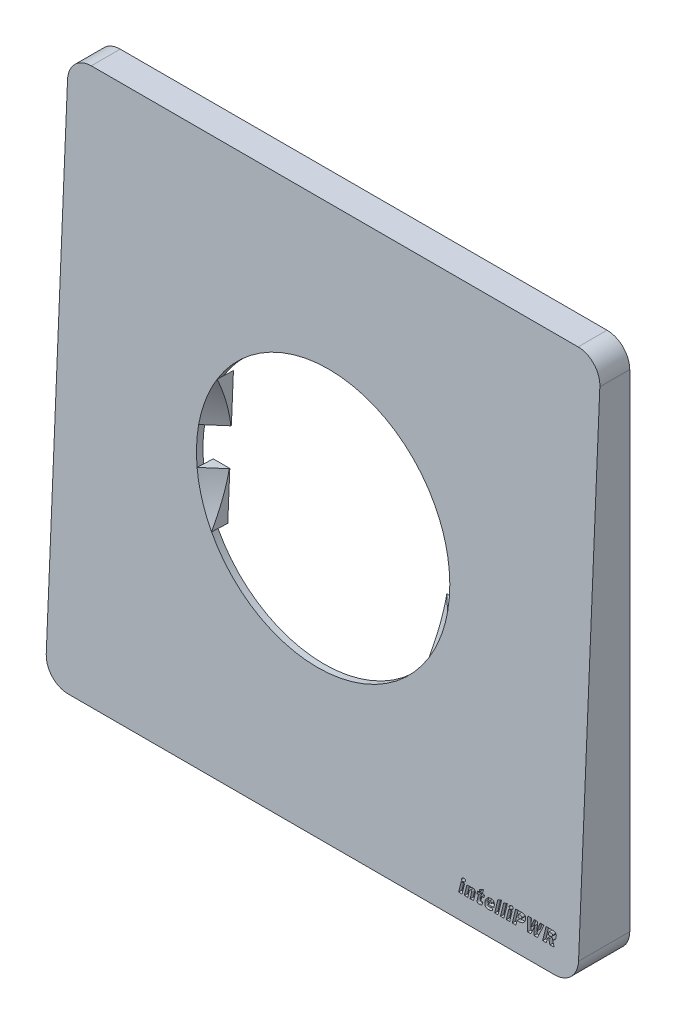
from build123d import *

# Parameters (mm, degrees)
EXTRUDE_THIN1_DEPTH         = 8
CUT_EXTRUDE2_DEPTH          = 120
BOSS_EXTRUDE1_DEPTH         = 82
CUT_EXTRUDE_THIN1_DEPTH     = 82
SKETCH8_R                   = 19.5
CUT_EXTRUDE3_DEPTH          = 82
CUT_EXTRUDE13_DEPTH         = 0.5
Y_KSEKLIK_EKSTR_ZYON1_DEPTH = 2.5
Y_KSEKLIK_EKSTR_ZYON4_REACH = 10.045
IZIM7_R                     = 5
IZIM8_W                     = 75
IZIM8_H                     = 75
KES_EKSTR_ZYON1_DEPTH       = 1.5
KES_EKSTR_ZYON2_DEPTH       = 3
IZIM11_R                    = 1.55
KES_EKSTR_ZYON3_DEPTH       = 2


with BuildPart() as part:
    # Sketch1 → Extrude-Thin1 (new body)
    with BuildSketch(Plane.XY):
        with BuildLine():
            Line((-37.5, 41), (37.5, 41))
            ThreePointArc((37.5, 41), (39.974873734, 39.974873734), (41, 37.5))
            Line((41, 37.5), (41, -37.5))
            ThreePointArc((41, -37.5), (39.974873734, -39.974873734), (37.5, -41))
            Line((37.5, -41), (-37.5, -41))
            ThreePointArc((-37.5, -41), (-39.974873734, -39.974873734), (-41, -37.5))
            Line((-41, -37.5), (-41, 37.5))
            ThreePointArc((-41, 37.5), (-39.974873734, 39.974873734), (-37.5, 41))
        make_face()
        with BuildLine():
            Line((-37.5, 40), (37.5, 40))
            ThreePointArc((37.5, 40), (39.267766953, 39.267766953), (40, 37.5))
            Line((40, 37.5), (40, -37.5))
            ThreePointArc((40, -37.5), (39.267766953, -39.267766953), (37.5, -40))
            Line((37.5, -40), (-37.5, -40))
            ThreePointArc((-37.5, -40), (-39.267766953, -39.267766953), (-40, -37.5))
            Line((-40, -37.5), (-40, 37.5))
            ThreePointArc((-40, 37.5), (-39.267766953, 39.267766953), (-37.5, 40))
        make_face(mode=Mode.SUBTRACT)
    extrude(amount=EXTRUDE_THIN1_DEPTH)

    # Sketch5 → Cut-Extrude2 (cut)
    with BuildSketch(Plane(origin=(41, 0, 0), x_dir=(0, 0, -1), z_dir=(1, 0, 0))):
        Polygon((-3.45625, 41), (-8, 41), (-8, -41), (-7.04375, -41), align=None)
    extrude(amount=-CUT_EXTRUDE2_DEPTH, mode=Mode.SUBTRACT)

    # Sketch6 → Boss-Extrude1 (add)
    with BuildSketch(Plane(origin=(41, 0, 0), x_dir=(0, 0, -1), z_dir=(1, 0, 0))):
        Polygon((-7.04375, -41), (-3.45625, 41), (-4.457206574, 41), (-8.044706574, -41), align=None)
    extrude(amount=-BOSS_EXTRUDE1_DEPTH)

    # Sketch7 → Cut-Extrude-Thin1 (cut)
    with BuildSketch(Plane(origin=(0, 0, 0), x_dir=(-1, 0, 0), z_dir=(0, 0, -1))):
        with BuildLine():
            Line((-37.5, 52), (37.5, 52))
            ThreePointArc((37.5, 52), (47.753048327, 47.753048327), (52, 37.5))
            Line((52, 37.5), (52, -37.5))
            ThreePointArc((52, -37.5), (47.753048327, -47.753048327), (37.5, -52))
            Line((37.5, -52), (-37.5, -52))
            ThreePointArc((-37.5, -52), (-47.753048327, -47.753048327), (-52, -37.5))
            Line((-52, -37.5), (-52, 37.5))
            ThreePointArc((-52, 37.5), (-47.753048327, 47.753048327), (-37.5, 52))
        make_face()
        with BuildLine():
            Line((-37.5, 41), (37.5, 41))
            ThreePointArc((37.5, 41), (39.974873734, 39.974873734), (41, 37.5))
            Line((41, 37.5), (41, -37.5))
            ThreePointArc((41, -37.5), (39.974873734, -39.974873734), (37.5, -41))
            Line((37.5, -41), (-37.5, -41))
            ThreePointArc((-37.5, -41), (-39.974873734, -39.974873734), (-41, -37.5))
            Line((-41, -37.5), (-41, 37.5))
            ThreePointArc((-41, 37.5), (-39.974873734, 39.974873734), (-37.5, 41))
        make_face(mode=Mode.SUBTRACT)
    extrude(amount=-CUT_EXTRUDE_THIN1_DEPTH, mode=Mode.SUBTRACT)

    # Sketch8 → Cut-Extrude3 (cut)
    with BuildSketch(Plane(origin=(0, 0.272956894, 6.23901471), x_dir=(1, 0, 0), z_dir=(0, 0.04370819, 0.99904434))):
        Circle(SKETCH8_R)
    extrude(amount=-CUT_EXTRUDE3_DEPTH, mode=Mode.SUBTRACT)

    # Sketch9 → Cut-Extrude13 (cut)
    with BuildSketch(Plane(origin=(0, 0.272956894, 6.23901471), x_dir=(1, 0, 0), z_dir=(0, 0.04370819, 0.99904434))):
        Polygon((22.531822821, -37.81243752), (22.856252467, -36.277424239), (23.382446053, -36.277424239), (23.058016406, -37.81243752), align=None)
        with BuildLine():
            Line((24.290595271, -37.81243752), (24.474593832, -36.930090398))
            add(Edge.make_bspline(
                [(24.474593832, -36.930090398), (24.478802242, -36.907040936), (24.485699122, -36.874149701), (24.489204408, -36.831864189), (24.489786804, -36.805005948), (24.488227016, -36.781187681), (24.484505468, -36.760299642), (24.478846794, -36.742301837), (24.467897911, -36.722954035), (24.449713773, -36.703469949), (24.410825862, -36.680379912), (24.375667943, -36.67553935), (24.351928125, -36.675453309)],
                knots=[0, 0, 0, 0, 0.206248224, 0.294567954, 0.37266766, 0.442257727, 0.504010297, 0.558886264, 0.607164005, 0.698384721, 0.78958017, 1, 1, 1, 1], degree=3))
            add(Edge.make_bspline(
                [(24.351928125, -36.675453309), (24.325473284, -36.67484558), (24.286525614, -36.681302878), (24.239553647, -36.702765608), (24.213865624, -36.721381884), (24.194964801, -36.739763636), (24.182562108, -36.757605017), (24.170154917, -36.777822133), (24.158964314, -36.801354271), (24.147757062, -36.827440773), (24.134571616, -36.86862437), (24.125790697, -36.901180323), (24.120978207, -36.924168606)],
                knots=[0, 0, 0, 0, 0.211446307, 0.310998659, 0.41131055, 0.464021143, 0.521401463, 0.584741643, 0.653943237, 0.72987757, 0.812025534, 1, 1, 1, 1], degree=3))
            Line((24.120978207, -36.924168606), (23.936556661, -37.81243752))
            Line((23.936556661, -37.81243752), (23.410363076, -37.81243752))
            Line((23.410363076, -37.81243752), (23.734792722, -36.26938752))
            Line((23.734792722, -36.26938752), (24.260986308, -36.26938752))
            Line((24.260986308, -36.26938752), (24.240683018, -36.373441879))
            add(Edge.make_bspline(
                [(24.240683018, -36.373441879), (24.297987543, -36.33807022), (24.373085655, -36.296555731), (24.471607475, -36.262409613), (24.549233248, -36.246533575), (24.610636762, -36.242418025), (24.653093586, -36.242316467)],
                knots=[0, 0, 0, 0, 0.46054381, 0.581347921, 0.710250487, 1, 1, 1, 1], degree=3))
            add(Edge.make_bspline(
                [(24.653093586, -36.242316467), (24.692136802, -36.242431818), (24.748815156, -36.246238609), (24.8195399, -36.26391656), (24.865428391, -36.281339933), (24.906090192, -36.304634337), (24.94136314, -36.333047361), (24.971485528, -36.366619173), (24.996169238, -36.405109022), (25.015420474, -36.448469614), (25.030965908, -36.495857326), (25.040105685, -36.548112348), (25.04586972, -36.604390706), (25.045678226, -36.66521683), (25.04090151, -36.755484326), (25.027642856, -36.824675469), (25.018552796, -36.872141426)],
                knots=[0, 0, 0, 0, 0.133987507, 0.193275728, 0.24925757, 0.301629359, 0.35316106, 0.403792674, 0.455518759, 0.509134706, 0.565968881, 0.625945932, 0.6905051, 0.759590801, 0.83411591, 1, 1, 1, 1], degree=3))
            Line((25.018552796, -36.872141426), (24.819749753, -37.81243752))
            Line((24.819749753, -37.81243752), (24.290595271, -37.81243752))
        make_face()
        with BuildLine():
            Line((25.394586637, -37.347153803), (25.534594737, -36.675453309))
            Line((25.534594737, -36.675453309), (25.300683923, -36.675453309))
            Line((25.300683923, -36.675453309), (25.388664844, -36.26938752))
            Line((25.388664844, -36.26938752), (25.622575658, -36.26938752))
            Line((25.622575658, -36.26938752), (25.704211801, -35.881087109))
            Line((25.704211801, -35.881087109), (26.259591365, -35.673824362))
            Line((26.259591365, -35.673824362), (26.133964762, -36.26938752))
            Line((26.133964762, -36.26938752), (26.467277097, -36.26938752))
            Line((26.467277097, -36.26938752), (26.379719161, -36.675453309))
            Line((26.379719161, -36.675453309), (26.046406826, -36.675453309))
            Line((26.046406826, -36.675453309), (25.929239926, -37.238869592))
            add(Edge.make_bspline(
                [(25.929239926, -37.238869592), (25.923631424, -37.263216042), (25.918218034, -37.297200918), (25.92312076, -37.33870405), (25.933824276, -37.360093), (25.95091673, -37.374576816), (25.981808804, -37.389433205), (26.009637148, -37.390972473), (26.028641447, -37.391567249)],
                knots=[0, 0, 0, 0, 0.332431059, 0.451864296, 0.549008946, 0.641835514, 0.743993136, 1, 1, 1, 1], degree=3))
            add(Edge.make_bspline(
                [(26.028641447, -37.391567249), (26.064780722, -37.392002115), (26.110181113, -37.38175387), (26.162442535, -37.359627978), (26.203981464, -37.340089416), (26.235299865, -37.32233029), (26.257053454, -37.309931106)],
                knots=[0, 0, 0, 0, 0.43902333, 0.560347006, 0.693743593, 1, 1, 1, 1], degree=3))
            Line((26.257053454, -37.309931106), (26.092935197, -37.757449444))
            add(Edge.make_bspline(
                [(26.092935197, -37.757449444), (26.033275974, -37.783688944), (25.9542673, -37.808911724), (25.856030319, -37.827809595), (25.785408909, -37.836780083), (25.731643106, -37.839786288), (25.695329112, -37.839508573)],
                knots=[0, 0, 0, 0, 0.477930884, 0.605353718, 0.733676339, 1, 1, 1, 1], degree=3))
            add(Edge.make_bspline(
                [(25.695329112, -37.839508573), (25.663071209, -37.839736582), (25.616436461, -37.836590683), (25.557875684, -37.82439235), (25.519836592, -37.812291359), (25.486172578, -37.796278005), (25.456955472, -37.776434565), (25.431516542, -37.753616181), (25.410851111, -37.726296633), (25.394665646, -37.694759799), (25.38251301, -37.658826153), (25.374110771, -37.618366346), (25.370071442, -37.573117994), (25.370413325, -37.523190221), (25.37572401, -37.446876072), (25.386376133, -37.387870854), (25.394586637, -37.347153803)],
                knots=[0, 0, 0, 0, 0.137072389, 0.197691701, 0.253760369, 0.306270191, 0.355445666, 0.403353528, 0.450794793, 0.500090506, 0.553319674, 0.611470956, 0.675245672, 0.745926336, 0.823383702, 1, 1, 1, 1], degree=3))
        make_face()
        with BuildLine():
            Line((27.91938528, -37.189803309), (27.01927278, -37.189803309))
            add(Edge.make_bspline(
                [(27.01927278, -37.189803309), (27.015898274, -37.226457242), (27.01601409, -37.279183424), (27.03669972, -37.341985199), (27.061308535, -37.376691917), (27.093763275, -37.402446593), (27.147771512, -37.428419222), (27.19477816, -37.432833272), (27.226535526, -37.433442783)],
                knots=[0, 0, 0, 0, 0.296055755, 0.414655706, 0.524028038, 0.631630635, 0.743271398, 1, 1, 1, 1], degree=3))
            add(Edge.make_bspline(
                [(27.226535526, -37.433442783), (27.260304962, -37.433236623), (27.31067195, -37.43030854), (27.376808197, -37.419896308), (27.426276206, -37.409482171), (27.476966935, -37.393776547), (27.552204889, -37.368515828), (27.608599837, -37.34239729), (27.647828783, -37.325158573)],
                knots=[0, 0, 0, 0, 0.230947891, 0.344109465, 0.457558095, 0.576207715, 0.70668566, 1, 1, 1, 1], degree=3))
            Line((27.647828783, -37.325158573), (27.779377179, -37.663123745))
            add(Edge.make_bspline(
                [(27.779377179, -37.663123745), (27.727053342, -37.69106355), (27.647293355, -37.728389628), (27.538548692, -37.768901332), (27.457845603, -37.794776995), (27.375596177, -37.814738758), (27.261882842, -37.834279371), (27.174496056, -37.839220378), (27.115713405, -37.839508573)],
                knots=[0, 0, 0, 0, 0.256454148, 0.380104154, 0.501569382, 0.622663836, 0.745735429, 1, 1, 1, 1], degree=3))
            add(Edge.make_bspline(
                [(27.115713405, -37.839508573), (27.062179079, -37.839286621), (26.984150161, -37.83327018), (26.88635986, -37.808329984), (26.821962158, -37.782879161), (26.764092487, -37.750669591), (26.712897628, -37.712208672), (26.667893943, -37.668395916), (26.62986787, -37.618343197), (26.599121942, -37.56243437), (26.574364264, -37.501573328), (26.556779358, -37.435320793), (26.545435886, -37.364186815), (26.541005333, -37.288550103), (26.544084404, -37.180061075), (26.556760714, -37.097618609), (26.568793544, -37.042181476)],
                knots=[0, 0, 0, 0, 0.139838784, 0.202933442, 0.262718436, 0.320042211, 0.375233846, 0.429352927, 0.483441981, 0.53862135, 0.595400523, 0.654488518, 0.717096367, 0.783082629, 0.851912792, 1, 1, 1, 1], degree=3))
            add(Edge.make_bspline(
                [(26.568793544, -37.042181476), (26.583085354, -36.979206373), (26.60848624, -36.887640456), (26.655114524, -36.772897044), (26.694694701, -36.695308707), (26.738238344, -36.623502999), (26.786046479, -36.557832048), (26.837870332, -36.498114858), (26.893872235, -36.444840081), (26.953078454, -36.39729059), (27.015434303, -36.35616866), (27.080683136, -36.32115439), (27.14867641, -36.29247145), (27.219054765, -36.270059906), (27.315753588, -36.248224211), (27.39033929, -36.242847847), (27.440143051, -36.242316467)],
                knots=[0, 0, 0, 0, 0.150666393, 0.221012111, 0.28851275, 0.353592776, 0.416668091, 0.477731317, 0.537737092, 0.596692125, 0.65460536, 0.711686431, 0.769156404, 0.826456793, 0.883737364, 1, 1, 1, 1], degree=3))
            add(Edge.make_bspline(
                [(27.440143051, -36.242316467), (27.48922651, -36.24267976), (27.561151065, -36.24758194), (27.651468494, -36.270502973), (27.711979381, -36.293016875), (27.766658046, -36.323010534), (27.815967781, -36.359353432), (27.859729134, -36.4023055), (27.897814959, -36.451871329), (27.929209579, -36.508297206), (27.953961332, -36.571393781), (27.97038317, -36.641490792), (27.980634306, -36.717983158), (27.982669075, -36.801137222), (27.975856843, -36.92586239), (27.959950401, -37.021979864), (27.946033347, -37.087863877)],
                knots=[0, 0, 0, 0, 0.12523536, 0.182281535, 0.236835406, 0.289223704, 0.340575345, 0.392377008, 0.444879637, 0.499220359, 0.55630156, 0.616919283, 0.68212815, 0.752543466, 0.82841511, 1, 1, 1, 1], degree=3))
            add(Edge.make_bspline(
                [(27.946033347, -37.087863877), (27.940848511, -37.106752883), (27.933318431, -37.141050311), (27.92588395, -37.175490124), (27.91938528, -37.189803309)],
                knots=[0, 0, 0, 0, 0.556454368, 1, 1, 1, 1], degree=3))
        make_face()
        with BuildLine():
            Line((27.089065337, -36.864950678), (27.527700987, -36.864950678))
            add(Edge.make_bspline(
                [(27.527700987, -36.864950678), (27.529337401, -36.829487736), (27.529026457, -36.77893147), (27.514215784, -36.717849161), (27.500871129, -36.6876486), (27.487156087, -36.667260541), (27.473605439, -36.655183968), (27.4583103, -36.644290122), (27.440041106, -36.635904218), (27.419470388, -36.629193279), (27.387146007, -36.622924997), (27.361546751, -36.621026515), (27.343702426, -36.621311204)],
                knots=[0, 0, 0, 0, 0.296748963, 0.41669466, 0.52130206, 0.570189777, 0.620055625, 0.671541666, 0.72618717, 0.786738208, 0.851474558, 1, 1, 1, 1], degree=3))
            add(Edge.make_bspline(
                [(27.343702426, -36.621311204), (27.315511409, -36.621200824), (27.27322467, -36.62837339), (27.223193569, -36.654754005), (27.18938015, -36.682031228), (27.158746996, -36.716815862), (27.120773112, -36.776433731), (27.10084266, -36.828342644), (27.089065337, -36.864950678)],
                knots=[0, 0, 0, 0, 0.222963425, 0.331063086, 0.443598367, 0.564296996, 0.69558842, 1, 1, 1, 1], degree=3))
        make_face(mode=Mode.SUBTRACT)
        Polygon((28.08138861, -37.81243752), (28.4874544, -35.884893976), (29.057638446, -35.673824362), (28.607582196, -37.81243752), align=None)
        Polygon((28.974733347, -37.81243752), (29.380799137, -35.884893976), (29.950983183, -35.673824362), (29.500926933, -37.81243752), align=None)
        Polygon((29.868078084, -37.81243752), (30.19250773, -36.277424239), (30.718701316, -36.277424239), (30.394271669, -37.81243752), align=None)
        with BuildLine():
            Line((31.772780428, -37.135661204), (31.489380345, -37.135661204))
            Line((31.489380345, -37.135661204), (31.34894926, -37.81243752))
            Line((31.34894926, -37.81243752), (30.790608799, -37.81243752))
            Line((30.790608799, -37.81243752), (31.223322656, -35.75503752))
            Line((31.223322656, -35.75503752), (32.103131867, -35.75503752))
            add(Edge.make_bspline(
                [(32.103131867, -35.75503752), (32.159534536, -35.754461725), (32.241971066, -35.759373362), (32.34812403, -35.774557347), (32.42051447, -35.790648003), (32.487750703, -35.810772195), (32.548378699, -35.837608583), (32.602942888, -35.869231698), (32.650276048, -35.907283046), (32.691096218, -35.950762718), (32.72462258, -36.000691089), (32.750395085, -36.056994678), (32.768534882, -36.119550733), (32.779127087, -36.188477535), (32.781433901, -36.294101393), (32.769834596, -36.376142847), (32.758335937, -36.432236821)],
                knots=[0, 0, 0, 0, 0.14831325, 0.216934671, 0.281917028, 0.343283354, 0.401251238, 0.455965678, 0.508744428, 0.560452414, 0.612307896, 0.666251039, 0.722712036, 0.783153078, 0.849210812, 1, 1, 1, 1], degree=3))
            add(Edge.make_bspline(
                [(32.758335937, -36.432236821), (32.745018379, -36.493400096), (32.720669996, -36.582253241), (32.670543899, -36.690589416), (32.628175407, -36.76221581), (32.579864514, -36.826142449), (32.527763822, -36.884522206), (32.469918315, -36.935510004), (32.407912463, -36.980860955), (32.341061715, -37.019087162), (32.270613234, -37.052413334), (32.195941581, -37.079438209), (32.117438362, -37.100302612), (32.035627861, -37.116510214), (31.920519083, -37.130666622), (31.832448592, -37.136469779), (31.772780428, -37.135661204)],
                knots=[0, 0, 0, 0, 0.14135813, 0.206506788, 0.268663819, 0.328624165, 0.386922124, 0.444795496, 0.502155746, 0.559848074, 0.618159034, 0.677698161, 0.738624222, 0.801161417, 0.865596376, 1, 1, 1, 1], degree=3))
        make_face()
        with BuildLine():
            Line((31.992309745, -36.215245415), (31.685222492, -36.215245415))
            Line((31.685222492, -36.215245415), (31.58582097, -36.675453309))
            Line((31.58582097, -36.675453309), (31.884025535, -36.675453309))
            add(Edge.make_bspline(
                [(31.884025535, -36.675453309), (31.925283313, -36.675209328), (31.984662794, -36.670227561), (32.055154824, -36.644667406), (32.096879938, -36.618845247), (32.130162263, -36.584340573), (32.167941671, -36.52744984), (32.183954356, -36.476480956), (32.191112788, -36.44111951)],
                knots=[0, 0, 0, 0, 0.290619666, 0.412091533, 0.523258856, 0.631698278, 0.745850168, 1, 1, 1, 1], degree=3))
            add(Edge.make_bspline(
                [(32.191112788, -36.44111951), (32.198110418, -36.410987258), (32.203090618, -36.36614806), (32.190734347, -36.310322247), (32.175987355, -36.281723428), (32.160016208, -36.261866207), (32.144631485, -36.249338003), (32.126367347, -36.238587545), (32.105357328, -36.229711955), (32.081040299, -36.223694155), (32.043444894, -36.216386171), (32.013189918, -36.215204357), (31.992309745, -36.215245415)],
                knots=[0, 0, 0, 0, 0.254137898, 0.360692933, 0.46331412, 0.514097368, 0.56812747, 0.624481852, 0.687008785, 0.753851467, 0.828927712, 1, 1, 1, 1], degree=3))
        make_face(mode=Mode.SUBTRACT)
        with BuildLine():
            Line((34.659231414, -37.81243752), (34.129230962, -37.81243752))
            Line((34.129230962, -37.81243752), (34.129230962, -37.365765152))
            add(Edge.make_bspline(
                [(34.129230962, -37.365765152), (34.126900951, -37.283994804), (34.128252893, -37.160536588), (34.13547643, -36.997616177), (34.140789961, -36.879311843), (34.146666584, -36.769053746), (34.151864415, -36.683348569), (34.155460175, -36.621114495), (34.160496198, -36.570625063), (34.164210151, -36.535200839), (34.167722615, -36.513449979)],
                knots=[0, 0, 0, 0, 0.287418182, 0.433706581, 0.573086252, 0.703582808, 0.821711634, 0.874841658, 0.922616611, 1, 1, 1, 1], degree=3))
            add(Edge.make_bspline(
                [(34.167722615, -36.513449979), (34.161496588, -36.535520096), (34.149299246, -36.570573469), (34.134017602, -36.621303223), (34.118978254, -36.666114788), (34.103325378, -36.714945055), (34.085340593, -36.766621059), (34.066093035, -36.820983598), (34.03725522, -36.897664284), (33.9987844, -36.997892012), (33.933873577, -37.161042447), (33.883548654, -37.284308092), (33.849214762, -37.365765152)],
                knots=[0, 0, 0, 0, 0.075537836, 0.122272145, 0.174582572, 0.231301047, 0.291254257, 0.354891756, 0.421348915, 0.56122885, 0.708689565, 1, 1, 1, 1], degree=3))
            Line((33.849214762, -37.365765152), (33.661832319, -37.81243752))
            Line((33.661832319, -37.81243752), (33.144521423, -37.81243752))
            Line((33.144521423, -37.81243752), (33.089110362, -35.75503752))
            Line((33.089110362, -35.75503752), (33.673675905, -35.75503752))
            Line((33.673675905, -35.75503752), (33.656333512, -36.098924485))
            add(Edge.make_bspline(
                [(33.656333512, -36.098924485), (33.65424701, -36.174983918), (33.648264891, -36.290478133), (33.63833161, -36.445240669), (33.629727747, -36.562669926), (33.621321528, -36.67807013), (33.607761646, -36.820968946), (33.598473633, -36.925344182), (33.591616776, -36.992269222)],
                knots=[0, 0, 0, 0, 0.254778508, 0.38725736, 0.519329184, 0.649081567, 0.774717154, 1, 1, 1, 1], degree=3))
            add(Edge.make_bspline(
                [(33.591616776, -36.992269222), (33.61165122, -36.925090754), (33.64627647, -36.821122294), (33.699313362, -36.68033524), (33.744037038, -36.566523172), (33.79127081, -36.450651757), (33.852019877, -36.294789455), (33.898907874, -36.178549694), (33.930850905, -36.101885382)],
                knots=[0, 0, 0, 0, 0.220629604, 0.344767136, 0.47349051, 0.605507784, 0.738597758, 1, 1, 1, 1], degree=3))
            Line((33.930850905, -36.101885382), (34.074242887, -35.75503752))
            Line((34.074242887, -35.75503752), (34.600436472, -35.75503752))
            Line((34.600436472, -35.75503752), (34.597475576, -36.101885382))
            add(Edge.make_bspline(
                [(34.597475576, -36.101885382), (34.595245322, -36.17885342), (34.593744967, -36.295183632), (34.59170112, -36.450432417), (34.58933481, -36.566770504), (34.585265185, -36.680726113), (34.576970765, -36.822355136), (34.568781216, -36.925808509), (34.562367804, -36.992269222)],
                knots=[0, 0, 0, 0, 0.259139328, 0.391547022, 0.522548461, 0.650759617, 0.775290273, 1, 1, 1, 1], degree=3))
            add(Edge.make_bspline(
                [(34.562367804, -36.992269222), (34.582394712, -36.924994766), (34.615222507, -36.82040396), (34.663469422, -36.677898334), (34.702776993, -36.562353946), (34.74497043, -36.44495472), (34.802596037, -36.290539958), (34.846106719, -36.175456577), (34.872415954, -36.098924485)],
                knots=[0, 0, 0, 0, 0.222643769, 0.347663635, 0.477213716, 0.609762054, 0.743343773, 1, 1, 1, 1], degree=3))
            Line((34.872415954, -36.098924485), (35.001003454, -35.75503752))
            Line((35.001003454, -35.75503752), (35.580070189, -35.75503752))
            Line((35.580070189, -35.75503752), (34.659231414, -37.81243752))
        make_face()
        with BuildLine():
            Line((36.593542722, -37.81243752), (36.406583265, -37.135661204))
            Line((36.406583265, -37.135661204), (36.178594243, -37.135661204))
            Line((36.178594243, -37.135661204), (36.032241365, -37.81243752))
            Line((36.032241365, -37.81243752), (35.473900905, -37.81243752))
            Line((35.473900905, -37.81243752), (35.906614762, -35.75503752))
            Line((35.906614762, -35.75503752), (36.821531743, -35.75503752))
            add(Edge.make_bspline(
                [(36.821531743, -35.75503752), (36.877926873, -35.754483807), (36.960384904, -35.759332471), (37.066505033, -35.774612626), (37.139020737, -35.790466145), (37.205953379, -35.811436437), (37.266900634, -35.837465743), (37.321219528, -35.86927989), (37.368651198, -35.906963709), (37.409975253, -35.949728838), (37.443119472, -35.999356773), (37.469792369, -36.054460359), (37.488179297, -36.116142105), (37.499234619, -36.184069182), (37.502091304, -36.288441986), (37.491138593, -36.369579554), (37.479273725, -36.425046073)],
                knots=[0, 0, 0, 0, 0.149105791, 0.218093904, 0.283423508, 0.345229253, 0.403357541, 0.458364359, 0.511192647, 0.563160888, 0.614984401, 0.668362726, 0.724518171, 0.784604297, 0.849908347, 1, 1, 1, 1], degree=3))
            add(Edge.make_bspline(
                [(37.479273725, -36.425046073), (37.471091951, -36.462370246), (37.457436855, -36.517331944), (37.43109931, -36.586817422), (37.410288931, -36.63589911), (37.386568462, -36.682146783), (37.360046921, -36.725521274), (37.331535273, -36.766605713), (37.289678358, -36.81710195), (37.232396706, -36.874721204), (37.129930057, -36.955845139), (37.043268199, -37.00306597), (36.982266118, -37.027799979)],
                knots=[0, 0, 0, 0, 0.140674907, 0.207617019, 0.273117689, 0.336661801, 0.398557529, 0.459984484, 0.520402942, 0.639569431, 0.758047993, 1, 1, 1, 1], degree=3))
            Line((36.982266118, -37.027799979), (37.228020518, -37.81243752))
            Line((37.228020518, -37.81243752), (36.593542722, -37.81243752))
        make_face()
        with BuildLine():
            Line((36.710709622, -36.215245415), (36.368514597, -36.215245415))
            Line((36.368514597, -36.215245415), (36.272073972, -36.675453309))
            Line((36.272073972, -36.675453309), (36.605386308, -36.675453309))
            add(Edge.make_bspline(
                [(36.605386308, -36.675453309), (36.646692183, -36.675332321), (36.705978767, -36.670056218), (36.776403605, -36.643820336), (36.817731516, -36.616951584), (36.851342385, -36.58260588), (36.88863205, -36.525830349), (36.904630746, -36.475608567), (36.912050576, -36.440696525)],
                knots=[0, 0, 0, 0, 0.291424493, 0.412585485, 0.525065724, 0.635142904, 0.748168098, 1, 1, 1, 1], degree=3))
            add(Edge.make_bspline(
                [(36.912050576, -36.440696525), (36.917844475, -36.411390256), (36.922675548, -36.366980493), (36.90794214, -36.31244527), (36.893225565, -36.28331352), (36.876706606, -36.263321356), (36.861459444, -36.249962849), (36.842692221, -36.239762671), (36.822035314, -36.229989575), (36.797925906, -36.22366887), (36.760859123, -36.216450838), (36.731169116, -36.215191251), (36.710709622, -36.215245415)],
                knots=[0, 0, 0, 0, 0.248424975, 0.356513751, 0.46136469, 0.51411026, 0.569240084, 0.626959334, 0.689288847, 0.756873603, 0.831295405, 1, 1, 1, 1], degree=3))
        make_face(mode=Mode.SUBTRACT)
        with BuildLine():
            add(Edge.make_bspline(
                [(23.50511176, -35.900967413), (23.49691936, -35.939534043), (23.47504383, -35.995133722), (23.425881126, -36.056740916), (23.380038303, -36.094110103), (23.328076843, -36.124265142), (23.249409757, -36.153091049), (23.185884765, -36.161544068), (23.142613446, -36.161103309)],
                knots=[0, 0, 0, 0, 0.243996234, 0.362518467, 0.483923593, 0.607810429, 0.732572499, 1, 1, 1, 1], degree=3))
            add(Edge.make_bspline(
                [(23.142613446, -36.161103309), (23.103364668, -36.161400076), (23.046373744, -36.154280511), (22.979352972, -36.124674591), (22.945948828, -36.099189041), (22.924597095, -36.074893347), (22.910930194, -36.055259817), (22.901500015, -36.033273015), (22.894040832, -36.01010401), (22.890391407, -35.984987846), (22.889303064, -35.948291927), (22.893286288, -35.92001209), (22.897282031, -35.900967413)],
                knots=[0, 0, 0, 0, 0.278361244, 0.398908763, 0.514847654, 0.572097947, 0.627438768, 0.683254165, 0.740686715, 0.799243397, 0.862127538, 1, 1, 1, 1], degree=3))
            add(Edge.make_bspline(
                [(22.897282031, -35.900967413), (22.90463722, -35.864843953), (22.926908821, -35.812948349), (22.975049057, -35.754537867), (23.02082171, -35.717115039), (23.07287559, -35.686103781), (23.14944575, -35.654434845), (23.212194736, -35.647389995), (23.253858553, -35.646753309)],
                knots=[0, 0, 0, 0, 0.233168972, 0.351345779, 0.477078281, 0.606225183, 0.734604908, 1, 1, 1, 1], degree=3))
            add(Edge.make_bspline(
                [(23.253858553, -35.646753309), (23.294043937, -35.647611873), (23.353611721, -35.652601871), (23.421520668, -35.685173743), (23.454901582, -35.711763501), (23.475557012, -35.736857178), (23.489276756, -35.75628574), (23.498634374, -35.777727473), (23.506206896, -35.800008962), (23.51029148, -35.823685041), (23.51182755, -35.85767362), (23.50937443, -35.883664153), (23.50511176, -35.900967413)],
                knots=[0, 0, 0, 0, 0.289932119, 0.415109387, 0.533191086, 0.591068146, 0.646913169, 0.702320899, 0.757398382, 0.814668092, 0.873137526, 1, 1, 1, 1], degree=3))
        make_face()
        with BuildLine():
            add(Edge.make_bspline(
                [(30.841367023, -35.900967413), (30.833174623, -35.939534043), (30.811299094, -35.995133722), (30.762136389, -36.056740916), (30.716293567, -36.094110103), (30.664332107, -36.124265142), (30.58566502, -36.153091049), (30.522140028, -36.161544068), (30.478868709, -36.161103309)],
                knots=[0, 0, 0, 0, 0.243996234, 0.362518467, 0.483923593, 0.607810429, 0.732572499, 1, 1, 1, 1], degree=3))
            add(Edge.make_bspline(
                [(30.478868709, -36.161103309), (30.439619931, -36.161400076), (30.382629007, -36.154280511), (30.315608235, -36.124674591), (30.282204092, -36.099189041), (30.260852358, -36.074893347), (30.247185457, -36.055259817), (30.237755278, -36.033273015), (30.230296095, -36.01010401), (30.226646671, -35.984987846), (30.225558327, -35.948291927), (30.229541551, -35.92001209), (30.233537294, -35.900967413)],
                knots=[0, 0, 0, 0, 0.278361244, 0.398908763, 0.514847654, 0.572097947, 0.627438768, 0.683254165, 0.740686715, 0.799243397, 0.862127538, 1, 1, 1, 1], degree=3))
            add(Edge.make_bspline(
                [(30.233537294, -35.900967413), (30.240892483, -35.864843953), (30.263164084, -35.812948349), (30.31130432, -35.754537867), (30.357076973, -35.717115039), (30.409130853, -35.686103781), (30.485701013, -35.654434845), (30.54845, -35.647389995), (30.590113816, -35.646753309)],
                knots=[0, 0, 0, 0, 0.233168972, 0.351345779, 0.477078281, 0.606225183, 0.734604908, 1, 1, 1, 1], degree=3))
            add(Edge.make_bspline(
                [(30.590113816, -35.646753309), (30.6302992, -35.647611873), (30.689866985, -35.652601871), (30.757775931, -35.685173743), (30.791156845, -35.711763501), (30.811812275, -35.736857178), (30.825532019, -35.75628574), (30.834889637, -35.777727473), (30.842462159, -35.800008962), (30.846546743, -35.823685041), (30.848082813, -35.85767362), (30.845629693, -35.883664153), (30.841367023, -35.900967413)],
                knots=[0, 0, 0, 0, 0.289932119, 0.415109387, 0.533191086, 0.591068146, 0.646913169, 0.702320899, 0.757398382, 0.814668092, 0.873137526, 1, 1, 1, 1], degree=3))
        make_face()
    extrude(amount=-CUT_EXTRUDE13_DEPTH, mode=Mode.SUBTRACT)

    # Çizim2 → Yükseklik-Ekstrüzyon1 (add)
    with BuildSketch(Plane(origin=(0, 0.272956894, 6.23901471), x_dir=(1, 0, 0), z_dir=(0, 0.04370819, 0.99904434))):
        with BuildLine():
            Line((-16.75, 2.8), (-16.75, 9.984362774))
            ThreePointArc((-16.75, 9.984362774), (-18.37843937, 6.517895851), (-19.29792735, 2.8))
            Line((-19.29792735, 2.8), (-16.75, 2.8))
        make_face()
        with BuildLine():
            ThreePointArc((-19.29792735, -2.8), (-18.37843937, -6.517895851), (-16.75, -9.984362774))
            Line((-16.75, -9.984362774), (-16.75, -2.8))
            Line((-16.75, -2.8), (-19.29792735, -2.8))
        make_face()
        with BuildLine():
            Line((16.75, 2.8), (19.29792735, 2.8))
            ThreePointArc((19.29792735, 2.8), (18.37843937, 6.517895851), (16.75, 9.984362774))
            Line((16.75, 9.984362774), (16.75, 2.8))
        make_face()
        with BuildLine():
            ThreePointArc((16.75, -9.984362774), (18.37843937, -6.517895851), (19.29792735, -2.8))
            Line((19.29792735, -2.8), (16.75, -2.8))
            Line((16.75, -2.8), (16.75, -9.984362774))
        make_face()
    extrude(amount=-Y_KSEKLIK_EKSTR_ZYON1_DEPTH)

    # Çizim4 → Kes-Döndür2 (revolve, cut)
    with BuildSketch(Plane(origin=(0, 0, 0), x_dir=(-1, 0, 0), z_dir=(0, -0.99904434, 0.04370819))):
        Polygon((19.5, -6.244982787), (16.9, -3.744982787), (16.9, -6.244982787), align=None)
    revolve(axis=Axis((0, -1.000417569, -22.866687299), (0, 0.04370819, 0.99904434)), mode=Mode.SUBTRACT)

    # Çizim7 → Yükseklik-Ekstrüzyon4 (add, up to next)
    with BuildSketch(Plane(origin=(0, 0, 0), x_dir=(-1, 0, 0), z_dir=(0, 0, -1)), mode=Mode.PRIVATE) as y_kseklik_ekstr_zyon4_sk1:
        with Locations((-29, -29)):
            Circle(IZIM7_R)
    y_kseklik_ekstr_zyon4_tool1 = extrude(y_kseklik_ekstr_zyon4_sk1.sketch, amount=-Y_KSEKLIK_EKSTR_ZYON4_REACH, mode=Mode.PRIVATE) - part.part
    add(y_kseklik_ekstr_zyon4_tool1.solids().sort_by_distance((29, -29, 0))[0])
    # Çizim7 → Yükseklik-Ekstrüzyon4 (add, up to next)
    with BuildSketch(Plane(origin=(0, 0, 0), x_dir=(-1, 0, 0), z_dir=(0, 0, -1)), mode=Mode.PRIVATE) as y_kseklik_ekstr_zyon4_sk2:
        with Locations((-29, 29)):
            Circle(IZIM7_R)
    y_kseklik_ekstr_zyon4_tool2 = extrude(y_kseklik_ekstr_zyon4_sk2.sketch, amount=-Y_KSEKLIK_EKSTR_ZYON4_REACH, mode=Mode.PRIVATE) - part.part
    add(y_kseklik_ekstr_zyon4_tool2.solids().sort_by_distance((29, 29, 0))[0])
    # Çizim7 → Yükseklik-Ekstrüzyon4 (add, up to next)
    with BuildSketch(Plane(origin=(0, 0, 0), x_dir=(-1, 0, 0), z_dir=(0, 0, -1)), mode=Mode.PRIVATE) as y_kseklik_ekstr_zyon4_sk3:
        with Locations((29, 29)):
            Circle(IZIM7_R)
    y_kseklik_ekstr_zyon4_tool3 = extrude(y_kseklik_ekstr_zyon4_sk3.sketch, amount=-Y_KSEKLIK_EKSTR_ZYON4_REACH, mode=Mode.PRIVATE) - part.part
    add(y_kseklik_ekstr_zyon4_tool3.solids().sort_by_distance((-29, 29, 0))[0])
    # Çizim7 → Yükseklik-Ekstrüzyon4 (add, up to next)
    with BuildSketch(Plane(origin=(0, 0, 0), x_dir=(-1, 0, 0), z_dir=(0, 0, -1)), mode=Mode.PRIVATE) as y_kseklik_ekstr_zyon4_sk4:
        with Locations((29, -29)):
            Circle(IZIM7_R)
    y_kseklik_ekstr_zyon4_tool4 = extrude(y_kseklik_ekstr_zyon4_sk4.sketch, amount=-Y_KSEKLIK_EKSTR_ZYON4_REACH, mode=Mode.PRIVATE) - part.part
    add(y_kseklik_ekstr_zyon4_tool4.solids().sort_by_distance((-29, -29, 0))[0])

    # Çizim8 → Kes-Ekstrüzyon1 (cut)
    with BuildSketch(Plane(origin=(0, 0, 0), x_dir=(-1, 0, 0), z_dir=(0, 0, -1))):
        Rectangle(IZIM8_W, IZIM8_H)
    extrude(amount=-KES_EKSTR_ZYON1_DEPTH, mode=Mode.SUBTRACT)

    # Çizim10 → Kes-Ekstrüzyon2 (cut)
    with BuildSketch(Plane.XZ.offset(41)):
        with BuildLine():
            Line((16.479145422, 4.388233566), (-16.479145422, 4.388233566))
            ThreePointArc((-16.479145422, 4.388233566), (-17.649333458, 4.150598487), (-18.634136343, 3.475340206))
            Line((-18.634136343, 3.475340206), (-22, 0))
            Line((-22, 0), (22, 0))
            Line((22, 0), (18.634136343, 3.475340206))
            ThreePointArc((18.634136343, 3.475340206), (17.649333458, 4.150598487), (16.479145422, 4.388233566))
        make_face()
    extrude(amount=-KES_EKSTR_ZYON2_DEPTH, mode=Mode.SUBTRACT)

    # Çizim11 → Kes-Ekstrüzyon3 (cut)
    with BuildSketch(Plane(origin=(0, 0, 1.5), x_dir=(-1, 0, 0), z_dir=(0, 0, -1))):
        with Locations((-29, 29)):
            Circle(IZIM11_R)
        with Locations((29, 29)):
            Circle(IZIM11_R)
        with Locations((29, -29)):
            Circle(IZIM11_R)
        with Locations((-29, -29)):
            Circle(IZIM11_R)
    extrude(amount=-KES_EKSTR_ZYON3_DEPTH, mode=Mode.SUBTRACT)


solid = part.part
